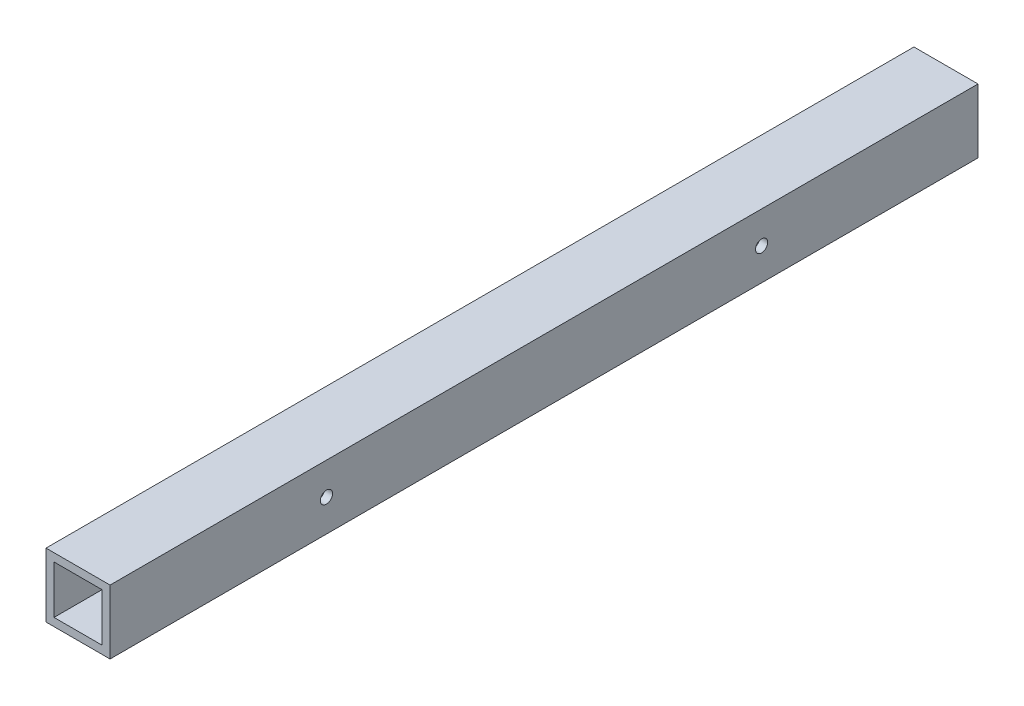
from build123d import *

# Parameters (mm, degrees)
SKETCH1_W           = 25.4
SKETCH1_H           = 25.4
SKETCH1_W_2         = 19.05
SKETCH1_H_2         = 19.05
EXTRUDE_THIN1_DEPTH = 344.17
SKETCH2_R           = 2.413
CUT_EXTRUDE1_DEPTH  = 26.4


with BuildPart() as part:
    # Sketch1 → Extrude-Thin1 (new body)
    with BuildSketch(Plane.XY):
        with Locations((12.7, 12.7)):
            Rectangle(SKETCH1_W, SKETCH1_H)
        with Locations((12.7, 12.7)):
            Rectangle(SKETCH1_W_2, SKETCH1_H_2, mode=Mode.SUBTRACT)
    extrude(amount=EXTRUDE_THIN1_DEPTH)

    # Sketch2 → Cut-Extrude1 (cut, through all)
    with BuildSketch(Plane(origin=(25.4, 0, 0), x_dir=(0, 0, -1), z_dir=(1, 0, 0))):
        with Locations((-85.8071055, 12.7)):
            Circle(SKETCH2_R)
        with Locations((-258.3628945, 12.7)):
            Circle(SKETCH2_R)
    extrude(amount=-CUT_EXTRUDE1_DEPTH, mode=Mode.SUBTRACT)


solid = part.part
